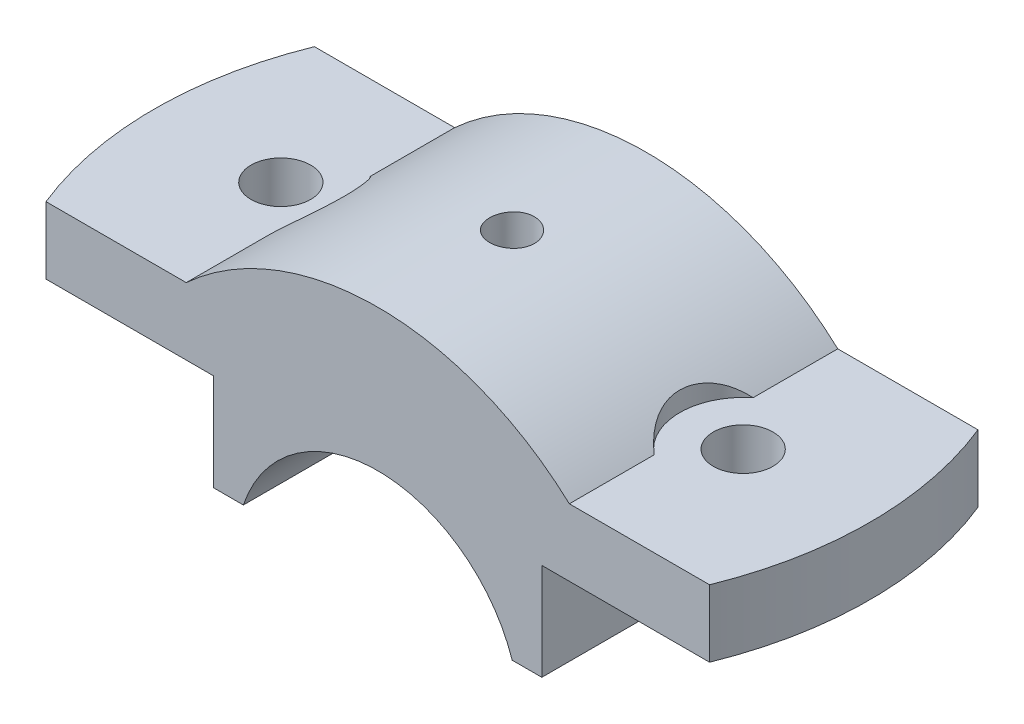
from build123d import *

# Parameters (mm, degrees)
BOSS_EXTRUDE1_DEPTH   = 18
F_8_0MM_DOWEL_HOLE1_D = 8
CUT_EXTRUDE1_DEPTH    = 36
CUT_EXTRUDE4_DEPTH    = 36


with BuildPart() as part:
    # Sketch2 → Boss-Extrude1 (new body, symmetric)
    with BuildSketch(Plane.XY):
        with BuildLine():
            Line((18.027756377, 0), (22, 0))
            Line((22, 0), (22, 13))
            Line((22, 13), (50, 13))
            Line((50, 13), (50, 22))
            Line((50, 22), (25.690465157, 22))
            ThreePointArc((25.690465157, 22), (0, 32), (-25.690465157, 22))
            Line((-25.690465157, 22), (-50, 22))
            Line((-50, 22), (-50, 13))
            Line((-50, 13), (-22, 13))
            Line((-22, 13), (-22, 0))
            Line((-22, 0), (-18.027756377, 0))
            ThreePointArc((-18.027756377, 0), (0, 13), (18.027756377, 0))
        make_face()
    extrude(amount=BOSS_EXTRUDE1_DEPTH, both=True)

    # Ø8.0mm Dowel Hole1 (through all)
    with Locations(Plane(origin=(0, 22, 0), x_dir=(1, 0, 0), z_dir=(0, 1, 0))):
        with Locations((-31, 0)):
            f_8_0mm_dowel_hole1 = Hole(F_8_0MM_DOWEL_HOLE1_D / 2)

    # Sketch9 → Cut-Extrude1 (cut)
    with BuildSketch(Plane(origin=(0, 22, 0), x_dir=(1, 0, 0), z_dir=(0, 1, 0))):
        with BuildLine():
            ThreePointArc((-44.497190923, -18), (-48, 0), (-44.497190923, 18))
            Line((-44.497190923, 18), (-50, 18))
            Line((-50, 18), (-50, -18))
            Line((-50, -18), (-44.497190923, -18))
        make_face()
    cut_extrude1 = extrude(amount=-CUT_EXTRUDE1_DEPTH, mode=Mode.SUBTRACT)

    # Mirror1: Ø8.0mm Dowel Hole1, Cut-Extrude1 across plane
    add(f_8_0mm_dowel_hole1.mirror(Plane(origin=(0, 0, 0), x_dir=(0, 0, 1), z_dir=(1, 0, 0))), mode=Mode.SUBTRACT)
    add(cut_extrude1.mirror(Plane(origin=(0, 0, 0), x_dir=(0, 0, 1), z_dir=(1, 0, 0))), mode=Mode.SUBTRACT)

    # Sketch10 → CBORE for M5 Hex Head Bolt1 (revolve, cut)
    with BuildSketch(Plane(origin=(0, 32, 0), x_dir=(0, 0, 1), z_dir=(1, 0, 0))):
        Polygon((0, 0), (0, 32), (2.5, 32), (2.5, 13.495), (2.995, 13), (3, 13), (3, 0), align=None)
    revolve(axis=Axis((0, 38.35, 0), (0, -1, 0)), mode=Mode.SUBTRACT)

    # Sketch12 → Cut-Extrude4 (cut)
    with BuildSketch(Plane(origin=(0, 22, 0), x_dir=(1, 0, 0), z_dir=(0, 1, 0))):
        with BuildLine():
            Line((-25.690465157, 6.637683312), (-25.690465157, -6.637683312))
            ThreePointArc((-25.690465157, -6.637683312), (-22.5, 0), (-25.690465157, 6.637683312))
        make_face()
    cut_extrude4 = extrude(amount=CUT_EXTRUDE4_DEPTH, mode=Mode.SUBTRACT)

    # Mirror2: Cut-Extrude4 across plane
    add(cut_extrude4.mirror(Plane(origin=(0, 0, 0), x_dir=(0, 0, 1), z_dir=(1, 0, 0))), mode=Mode.SUBTRACT)


solid = part.part
